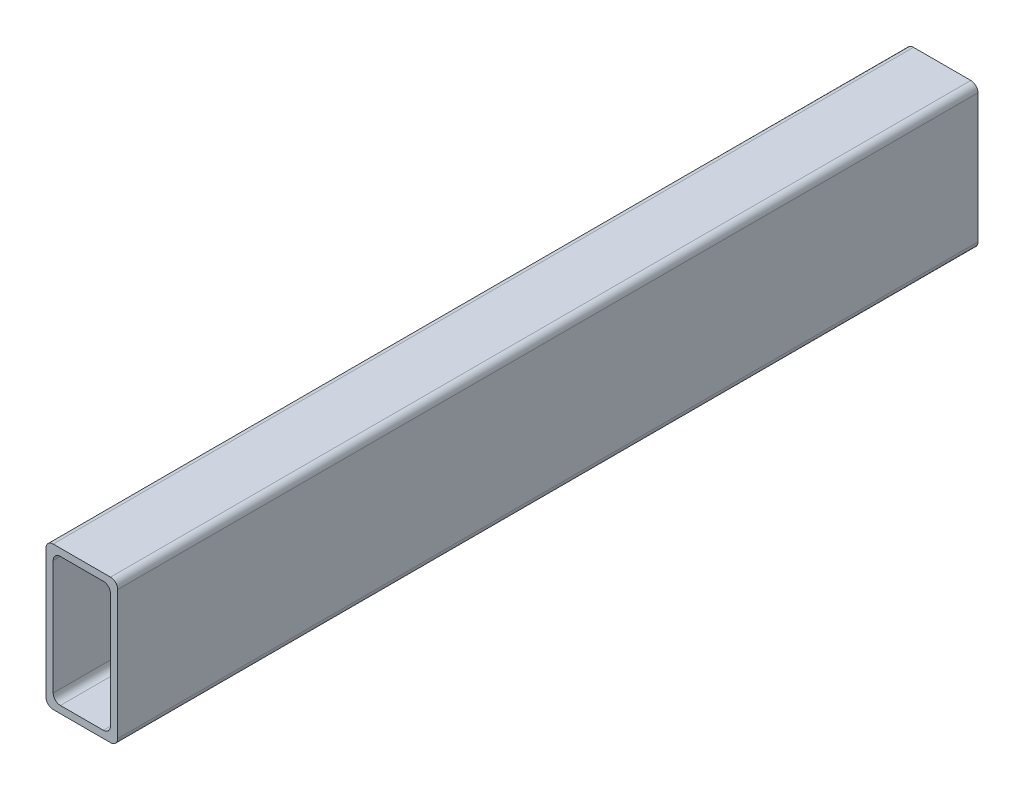
from build123d import *

# Parameters (mm, degrees)
EXTRUDE_1_DEPTH = 300


with BuildPart() as part:
    # Эскиз1 → Бобышка-Вытянуть1 (new body)
    with BuildSketch(Plane.XY):
        with BuildLine():
            Line((-10, 50), (10, 50))
            ThreePointArc((10, 50), (11.767766953, 49.267766953), (12.5, 47.5))
            Line((12.5, 47.5), (12.5, 2.5))
            ThreePointArc((12.5, 2.5), (11.767766953, 0.732233047), (10, 0))
            Line((10, 0), (-10, 0))
            ThreePointArc((-10, 0), (-11.767766953, 0.732233047), (-12.5, 2.5))
            Line((-12.5, 2.5), (-12.5, 47.5))
            ThreePointArc((-12.5, 47.5), (-11.767766953, 49.267766953), (-10, 50))
        make_face()
        with BuildLine():
            Line((-7.5, 47.5), (7.5, 47.5))
            ThreePointArc((7.5, 47.5), (9.267766953, 46.767766953), (10, 45))
            Line((10, 45), (10, 5))
            ThreePointArc((10, 5), (9.267766953, 3.232233047), (7.5, 2.5))
            Line((7.5, 2.5), (-7.5, 2.5))
            ThreePointArc((-7.5, 2.5), (-9.267766953, 3.232233047), (-10, 5))
            Line((-10, 5), (-10, 45))
            ThreePointArc((-10, 45), (-9.267766953, 46.767766953), (-7.5, 47.5))
        make_face(mode=Mode.SUBTRACT)
    extrude(amount=-EXTRUDE_1_DEPTH)


solid = part.part
